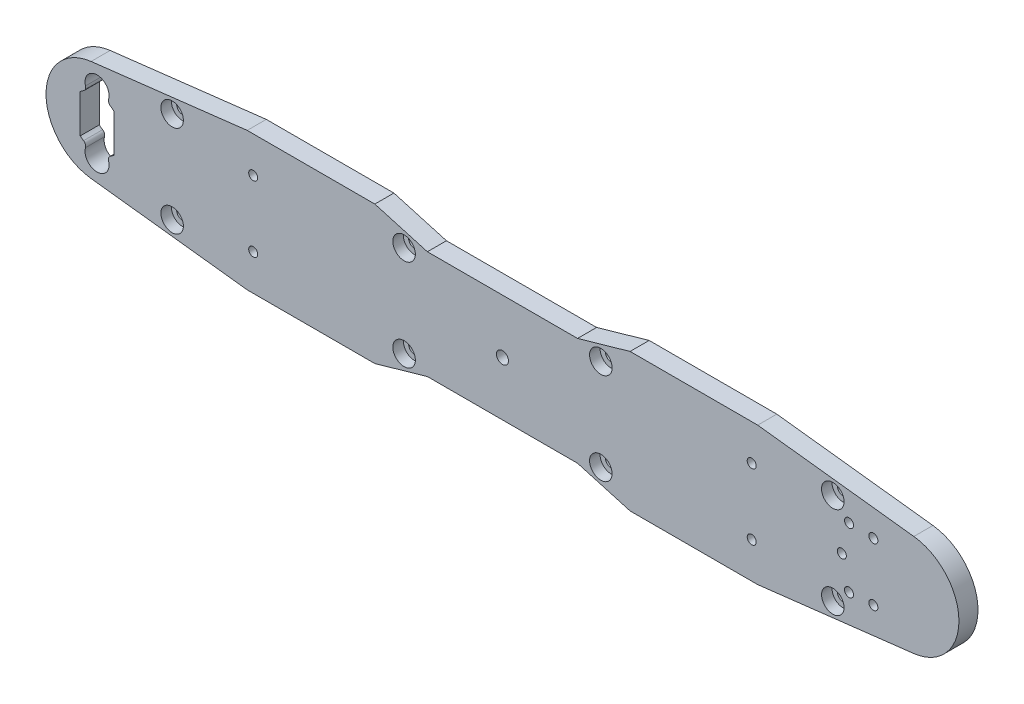
from build123d import *

# Parameters (mm, degrees)
SALIENTE_EXTRUIR1_DEPTH = 6.35
CROQUIS3_R              = 1.5
CROQUIS3_R_2            = 2
CORTAR_EXTRUIR2_DEPTH   = 7.35
CORTAR_EXTRUIR3_DEPTH   = 56
REDONDEO2_R             = 1.5
CROQUIS5_R              = 2
CORTAR_EXTRUIR5_DEPTH   = 7.3500001
CROQUIS7_R              = 3.75
CORTAR_EXTRUIR6_DEPTH   = 3.5
CROQUIS8_R              = 1.5
CORTAR_EXTRUIR7_DEPTH   = 7.3500001


with BuildPart() as part:
    # Croquis1 → Saliente-Extruir1 (new body)
    with BuildSketch(Plane.XY):
        with BuildLine():
            Line((92.5, 23), (50, 23))
            Line((50, 23), (-1.986430717, 16.883545037))
            ThreePointArc((-1.986430717, 16.883545037), (-17, 0), (-1.986430717, -16.883545037))
            Line((-1.986430717, -16.883545037), (50, -23))
            Line((50, -23), (92.5, -23))
            Line((92.5, -23), (110, -18))
            Line((110, -18), (160, -18))
            Line((160, -18), (177.5, -23))
            Line((177.5, -23), (220, -23))
            Line((220, -23), (271.986430717, -16.883545037))
            ThreePointArc((271.986430717, -16.883545037), (287, 0), (271.986430717, 16.883545037))
            Line((271.986430717, 16.883545037), (220, 23))
            Line((220, 23), (177.5, 23))
            Line((177.5, 23), (160, 18))
            Line((160, 18), (110, 18))
            Line((110, 18), (92.5, 23))
        make_face()
    extrude(amount=SALIENTE_EXTRUIR1_DEPTH)

    # Croquis3 → Cortar-Extruir2 (cut, through all)
    with BuildSketch(Plane.XY.offset(6.35)):
        with Locations((52, 11)):
            Circle(CROQUIS3_R)
        with Locations((52, -11)):
            Circle(CROQUIS3_R)
        with Locations((218, -11)):
            Circle(CROQUIS3_R)
        with Locations((218, 11)):
            Circle(CROQUIS3_R)
        with Locations((135, 0)):
            Circle(CROQUIS3_R_2)
    extrude(amount=-CORTAR_EXTRUIR2_DEPTH, mode=Mode.SUBTRACT)

    # Croquis2 → Cortar-Extruir3 (cut)
    with BuildSketch(Plane.XY.offset(6.35)):
        with BuildLine():
            ThreePointArc((-3.348857081, 7.8125), (-4.530250685, 7.19213659), (-5.6, 6.394528911))
            Line((-5.6, 6.394528911), (-5.6, -6.394528911))
            ThreePointArc((-5.6, -6.394528911), (-4.530250685, -7.19213659), (-3.348857081, -7.8125))
            ThreePointArc((-3.348857081, -7.8125), (0, -14), (3.348857081, -7.8125))
            ThreePointArc((3.348857081, -7.8125), (4.530250685, -7.19213659), (5.6, -6.394528911))
            Line((5.6, -6.394528911), (5.6, 6.394528911))
            ThreePointArc((5.6, 6.394528911), (4.530250685, 7.19213659), (3.348857081, 7.8125))
            ThreePointArc((3.348857081, 7.8125), (0, 14), (-3.348857081, 7.8125))
        make_face()
    extrude(amount=-CORTAR_EXTRUIR3_DEPTH, mode=Mode.SUBTRACT)

    # Redondeo2
    redondeo2_edges = [part.edges().sort_by_distance(p)[0] for p in [
        (-3.348857081, 7.8125, 3.175),
        (3.348857081, 7.8125, 3.175),
        (3.348857081, -7.8125, 3.175),
        (-3.348857081, -7.8125, 3.175),
    ]]
    fillet(redondeo2_edges, radius=REDONDEO2_R)

    # Croquis5 → Cortar-Extruir5 (cut, through all)
    with BuildSketch(Plane.XY.offset(6.35)):
        with Locations((25, 15.263279564)):
            Circle(CROQUIS5_R)
        with Locations((25, -15.263279564)):
            Circle(CROQUIS5_R)
        with Locations((102.242759853, 15.263279564)):
            Circle(CROQUIS5_R)
        with Locations((102.242759853, -15.263279564)):
            Circle(CROQUIS5_R)
        with Locations((167.757240147, -15.263279564)):
            Circle(CROQUIS5_R)
        with Locations((167.757240147, 15.263279564)):
            Circle(CROQUIS5_R)
        with Locations((245, 15.263279564)):
            Circle(CROQUIS5_R)
        with Locations((245, -15.263279564)):
            Circle(CROQUIS5_R)
    extrude(amount=-CORTAR_EXTRUIR5_DEPTH, mode=Mode.SUBTRACT)

    # Croquis7 → Cortar-Extruir6 (cut)
    with BuildSketch(Plane.XY.offset(6.35)):
        with Locations((25, 15.263279564)):
            Circle(CROQUIS7_R)
        with Locations((25, -15.263279564)):
            Circle(CROQUIS7_R)
        with Locations((245, 15.263279564)):
            Circle(CROQUIS7_R)
        with Locations((245, -15.263279564)):
            Circle(CROQUIS7_R)
        with Locations((102.242759853, 15.263279564)):
            Circle(CROQUIS7_R)
        with Locations((102.242759853, -15.263279564)):
            Circle(CROQUIS7_R)
        with Locations((167.757240147, -15.263279564)):
            Circle(CROQUIS7_R)
        with Locations((167.757240147, 15.263279564)):
            Circle(CROQUIS7_R)
    extrude(amount=-CORTAR_EXTRUIR6_DEPTH, mode=Mode.SUBTRACT)

    # Croquis8 → Cortar-Extruir7 (cut, through all)
    with BuildSketch(Plane.XY.offset(6.35)):
        with Locations((248, 0)):
            Circle(CROQUIS8_R)
        with Locations((250.397856468, 9.987790994)):
            Circle(CROQUIS8_R)
        with Locations((258.509333353, 9.641814145)):
            Circle(CROQUIS8_R)
        with Locations((258.509333353, -9.641814145)):
            Circle(CROQUIS8_R)
        with Locations((250.397856468, -9.987790994)):
            Circle(CROQUIS8_R)
    extrude(amount=-CORTAR_EXTRUIR7_DEPTH, mode=Mode.SUBTRACT)


solid = part.part
